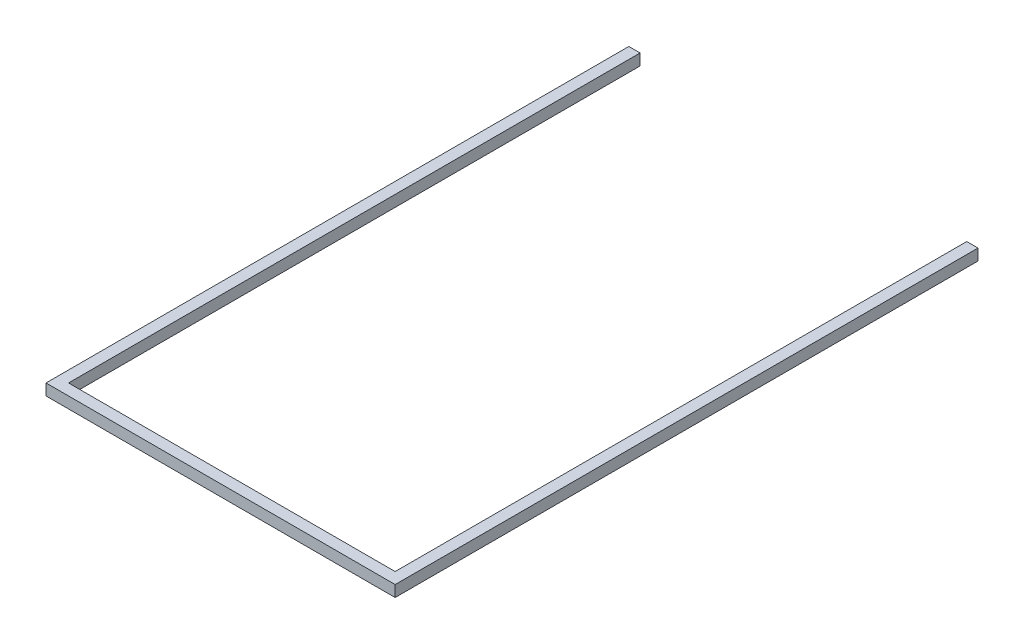
from build123d import *

# Parameters (mm, degrees)
BOSS_EXTRUDE1_DEPTH = 20


with BuildPart() as part:
    # Sketch1 → Boss-Extrude1 (new body)
    with BuildSketch(Plane(origin=(0, 0, 0), x_dir=(1, 0, 0), z_dir=(0, 1, 0))):
        Polygon((-81.144259733, 976.78781367), (-81.144259733, -58.21218633), (538.855740267, -58.21218633), (538.855740267, 976.78781367), (518.855740267, 976.78781367), (518.855740267, -38.21218633), (-61.144259733, -38.21218633), (-61.144259733, 976.78781367), align=None)
    extrude(amount=BOSS_EXTRUDE1_DEPTH)


solid = part.part
